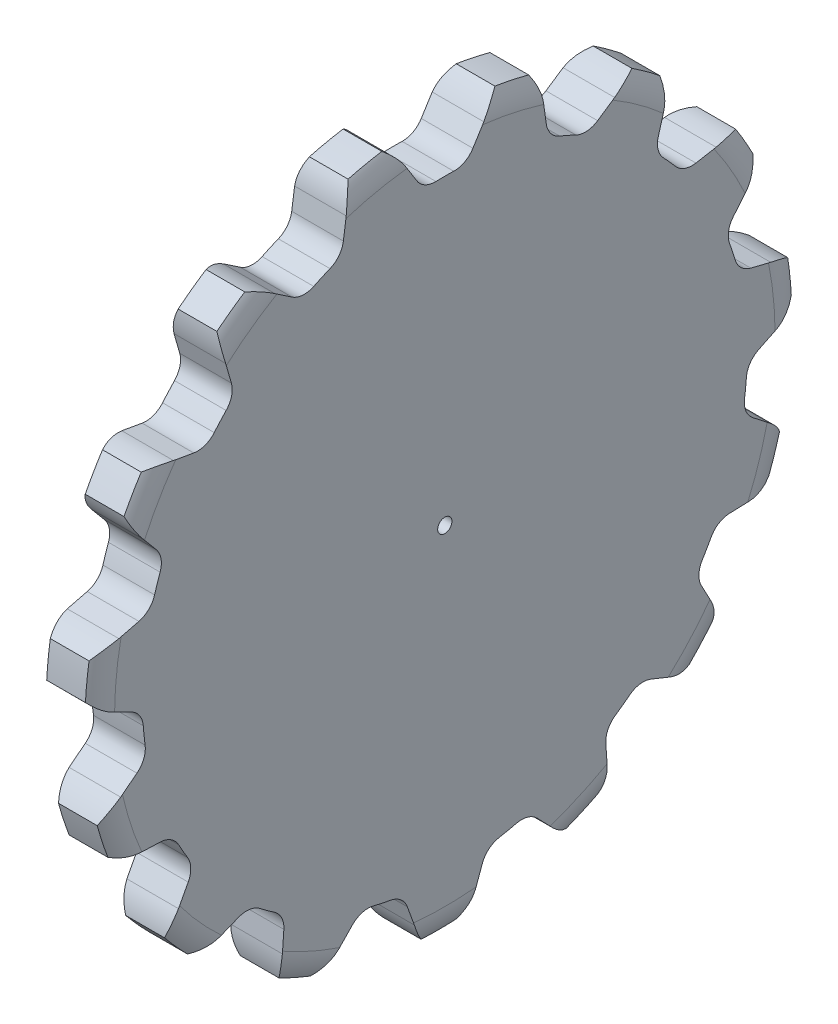
from build123d import *

# Parameters (mm, degrees)
TOOTHCUT_DEPTH  = 9.636
TEETHCUTS_COUNT = 15
TEETHCUTS_ANGLE = 336
BORSKE_R        = 1.19126
BORE_DEPTH      = 50.8000508


with BuildPart() as part:
    # BasProSke → Base-Revolve (revolve)
    with BuildSketch(Plane(origin=(0, 0, 0), x_dir=(1, 0, 0), z_dir=(0, 1, 0))):
        with BuildLine():
            Line((0, 0), (0, 55.219598127))
            ThreePointArc((0, 55.219598127), (0.274889268, 57.236270553), (1.0795, 59.105798127))
            Line((1.0795, 59.105798127), (7.5565, 59.105798127))
            ThreePointArc((7.5565, 59.105798127), (8.361110732, 57.236270553), (8.636, 55.219598127))
            Line((8.636, 55.219598127), (8.636, 0))
            Line((8.636, 0), (0, 0))
        make_face()
    revolve(axis=Axis((-10, 0, 0), (1, 0, 0)))

    # TooCutSke → ToothCut (cut, through all)
    with BuildSketch(Plane(origin=(0, 0, 0), x_dir=(0, 0, -1), z_dir=(1, 0, 0))):
        with BuildLine():
            Line((-4.697782177, 52.260643466), (-6.522951304, 55.18152464))
            ThreePointArc((-6.522951304, 55.18152464), (-9.211151, 58.160379089), (-12.760248512, 60.032249354))
            ThreePointArc((-12.760248512, 60.032249354), (0, 61.373405516), (12.760248512, 60.032249354))
            ThreePointArc((12.760248512, 60.032249354), (9.211151, 58.160379089), (6.522951304, 55.18152464))
            Line((6.522951304, 55.18152464), (4.697782177, 52.260643466))
            ThreePointArc((4.697782177, 52.260643466), (3.321924713, 50.974114375), (1.488304994, 50.542860871))
            ThreePointArc((1.488304994, 50.542860871), (0, 50.56476873), (-1.488304994, 50.542860871))
            ThreePointArc((-1.488304994, 50.542860871), (-3.321924713, 50.974114375), (-4.697782177, 52.260643466))
        make_face()
    toothcut = extrude(amount=TOOTHCUT_DEPTH, mode=Mode.SUBTRACT)

    # TeethCuts: ToothCut ×15 about axis
    teethcuts_axis = Axis((-10, 0, 0), (1, 0, 0))
    for i in range(1, TEETHCUTS_COUNT):
        add(toothcut.rotate(teethcuts_axis, i * TEETHCUTS_ANGLE / (TEETHCUTS_COUNT - 1)), mode=Mode.SUBTRACT)

    # BorSke → Bore (cut, symmetric)
    with BuildSketch(Plane(origin=(0, 0, 0), x_dir=(0, 0, -1), z_dir=(1, 0, 0))):
        Circle(BORSKE_R)
    extrude(amount=BORE_DEPTH, both=True, mode=Mode.SUBTRACT)


solid = part.part
